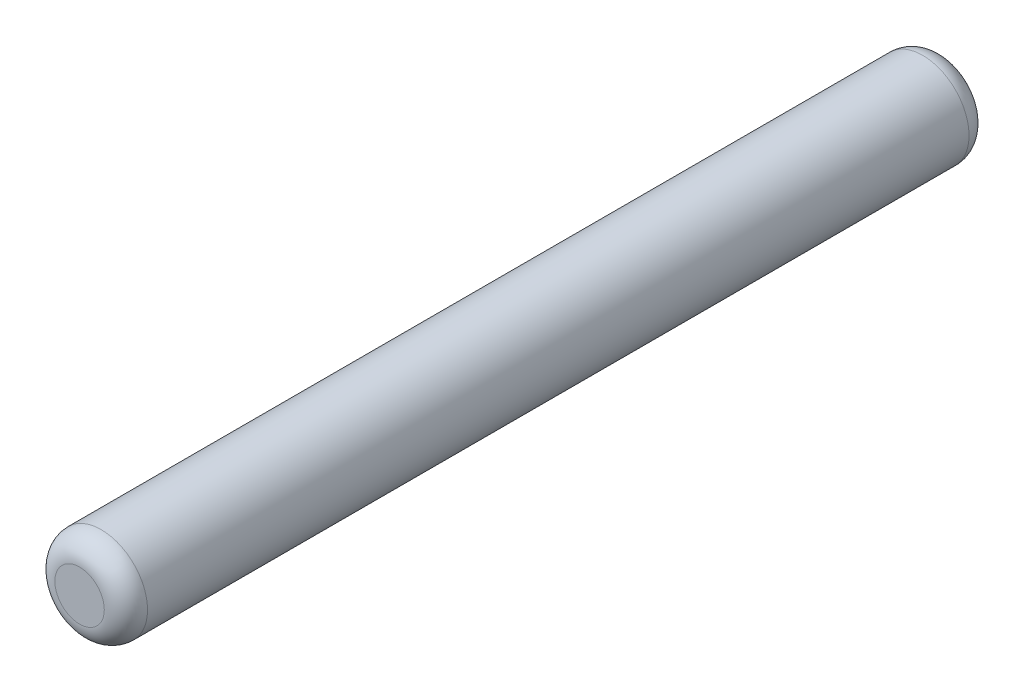
from build123d import *

# Parameters (mm, degrees)
SKETCH1_R           = 0.75
BOSS_EXTRUDE1_DEPTH = 7
FILLET1_R           = 0.35


with BuildPart() as part:
    # Sketch1 → Boss-Extrude1 (new body, symmetric)
    with BuildSketch(Plane.XY):
        Circle(SKETCH1_R)
    extrude(amount=BOSS_EXTRUDE1_DEPTH, both=True)

    # Fillet1
    fillet1_edges = [part.edges().sort_by_distance(p)[0] for p in [
        (-0.75, 0, -7),
        (-0.75, 0, 7),
    ]]
    fillet(fillet1_edges, radius=FILLET1_R)


solid = part.part
